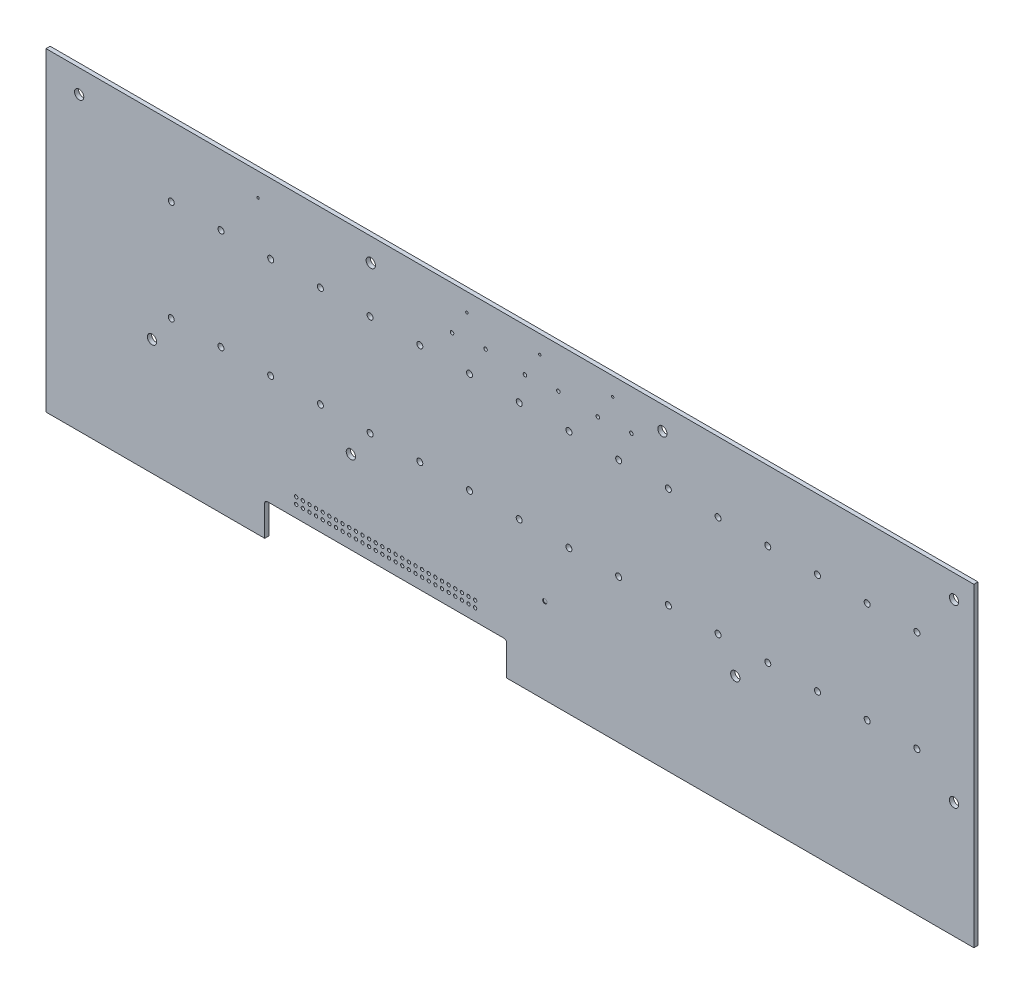
from build123d import *

# Parameters (mm, degrees)
SKETCH1_W                    = 355.6
SKETCH1_H                    = 120.65
EXTRUDE1_DEPTH               = 1.5748
DSPBOARD_CONNECTOR_HOLES_R   = 1.15
CUT_EXTRUDE1_DEPTH           = 2.54
LPATTERN1_COUNT              = 16
LPATTERN1_PITCH              = 19.05
SKETCH2_R                    = 1.778
PCB_MOUNT_HOLES_DEPTH        = 2.54
SKETCH6_R                    = 0.675005
PERIPHERAL_SATA_DEPTH        = 2.54
SKETCH7_R                    = 0.4499991
SKETCH7_R_2                  = 0.449961
OFF_BOARD_HEADER_HOLES_DEPTH = 2.54
NIC_CUTOUT_DEPTH             = 2.54
SKETCH10_R                   = 0.635
HEADER_HOLES_DEPTH           = 2.54
BGA_MOUNT_POS_R              = 0.838088067
CUT_EXTRUDE11_DEPTH          = 0.254
LPATTERN3_COUNT              = 28
LPATTERN3_PITCH              = 2.54
LPATTERN3_COUNT_DIR2         = 2
LPATTERN3_PITCH_DIR2         = 2.54
LPATTERN4_COUNT              = 3
LPATTERN4_PITCH              = 27.94


with BuildPart() as part:
    # Sketch1 → Extrude1 (new body)
    with BuildSketch(Plane.XY):
        with Locations((177.8, -60.325)):
            Rectangle(SKETCH1_W, SKETCH1_H)
    extrude(amount=EXTRUDE1_DEPTH)

    # DSPboard connector holes → Cut-Extrude1 (cut)
    with BuildSketch(Plane.XY.offset(1.5748)):
        with Locations((48.006, -65.532)):
            Circle(DSPBOARD_CONNECTOR_HOLES_R)
        with Locations((48.006, -26.802)):
            Circle(DSPBOARD_CONNECTOR_HOLES_R)
    cut_extrude1 = extrude(amount=-CUT_EXTRUDE1_DEPTH, mode=Mode.SUBTRACT)

    # LPattern1: Cut-Extrude1 ×16
    with Locations(*[(i * LPATTERN1_PITCH, 0, 0) for i in range(1, LPATTERN1_COUNT)]):
        add(cut_extrude1, mode=Mode.SUBTRACT)

    # Sketch2 → PCB Mount holes (cut)
    with BuildSketch(Plane.XY.offset(1.5748)):
        with Locations((12.7, -8.89)):
            Circle(SKETCH2_R)
        with Locations((124.46, -8.89)):
            Circle(SKETCH2_R)
        with Locations((236.22, -8.89)):
            Circle(SKETCH2_R)
        with Locations((347.98, -8.89)):
            Circle(SKETCH2_R)
        with Locations((40.64, -76.2)):
            Circle(SKETCH2_R)
        with Locations((116.84, -76.2)):
            Circle(SKETCH2_R)
        with Locations((264.16, -76.2)):
            Circle(SKETCH2_R)
        with Locations((347.98, -76.2)):
            Circle(SKETCH2_R)
    extrude(amount=-PCB_MOUNT_HOLES_DEPTH, mode=Mode.SUBTRACT)

    # Sketch6 → Peripheral-SATA (cut)
    with BuildSketch(Plane.XY.offset(1.5748)):
        with Locations((168.4383248, -15.51)):
            Circle(SKETCH6_R)
        with Locations((155.6083248, -16.51)):
            Circle(SKETCH6_R)
    peripheral_sata = extrude(amount=-PERIPHERAL_SATA_DEPTH, mode=Mode.SUBTRACT)

    # Sketch7 → Off-board header holes (cut)
    with BuildSketch(Plane.XY.offset(1.5748)):
        with Locations((217.17, -6.985)):
            Circle(SKETCH7_R)
        with Locations((189.23, -6.985)):
            Circle(SKETCH7_R_2)
        with Locations((161.29, -6.985)):
            Circle(SKETCH7_R_2)
        with Locations((81.28, -8.89)):
            Circle(SKETCH7_R_2)
    extrude(amount=-OFF_BOARD_HEADER_HOLES_DEPTH, mode=Mode.SUBTRACT)

    # Sketch9 → NIC cutout (cut)
    with BuildSketch(Plane.XY.offset(1.5748)):
        with BuildLine():
            Line((84.836, -107.95), (175.514, -107.95))
            ThreePointArc((175.514, -107.95), (176.23242049, -108.24757951), (176.53, -108.966))
            Line((176.53, -108.966), (176.53, -120.65))
            Line((176.53, -120.65), (83.82, -120.65))
            Line((83.82, -120.65), (83.82, -108.966))
            ThreePointArc((83.82, -108.966), (84.11757951, -108.24757951), (84.836, -107.95))
        make_face()
    extrude(amount=-NIC_CUTOUT_DEPTH, mode=Mode.SUBTRACT)

    # Sketch10 → Header Holes (cut)
    with BuildSketch(Plane.XY.offset(1.5748)):
        with Locations((164.465, -100.838)):
            Circle(SKETCH10_R)
    header_holes = extrude(amount=-HEADER_HOLES_DEPTH, mode=Mode.SUBTRACT)

    # BGA mount pos → Cut-Extrude11 (cut)
    with BuildSketch(Plane.XY.offset(1.5748)):
        with Locations((191.2, -87.85)):
            Circle(BGA_MOUNT_POS_R)
    extrude(amount=-CUT_EXTRUDE11_DEPTH, mode=Mode.SUBTRACT)

    # LPattern3: Header Holes 28 × 2
    with Locations(*[(-i * LPATTERN3_PITCH, -j * LPATTERN3_PITCH_DIR2, 0) for i in range(LPATTERN3_COUNT) for j in range(LPATTERN3_COUNT_DIR2) if (i, j) != (0, 0)]):
        add(header_holes, mode=Mode.SUBTRACT)

    # LPattern4: Peripheral-SATA ×3
    with Locations(*[(i * LPATTERN4_PITCH, 0, 0) for i in range(1, LPATTERN4_COUNT)]):
        add(peripheral_sata, mode=Mode.SUBTRACT)


solid = part.part
